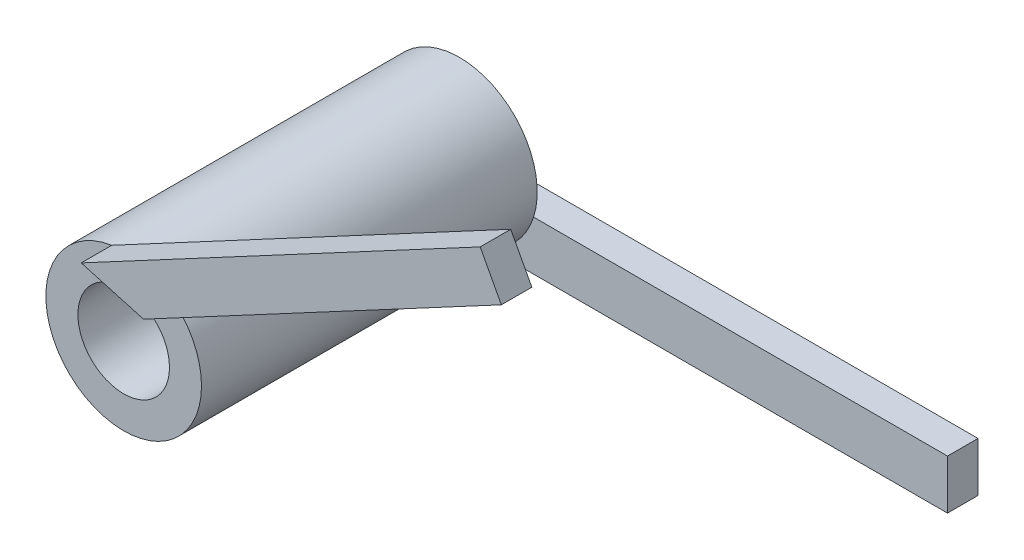
from build123d import *

# Parameters (mm, degrees)
SKETCH1_R      = 2.55
EXTRUDE1_DEPTH = 11
EXTRUDE2_DEPTH = 1
SKETCH3_W      = 15.099881368
SKETCH3_H      = 1.61958708
EXTRUDE3_DEPTH = 1
SKETCH4_R      = 1.5
EXTRUDE4_DEPTH = 13


with BuildPart() as part:
    # Sketch1 → Extrude1 (new body)
    with BuildSketch(Plane.XY):
        Circle(SKETCH1_R)
    extrude(amount=EXTRUDE1_DEPTH)

    # Sketch2 → Extrude2 (add)
    with BuildSketch(Plane.XY.offset(11)):
        Polygon((1.650889975, 1.943466565), (13.374427377, 8.212697839), (12.680705309, 9.509966398), (-0.390866423, 2.519865758), align=None)
    extrude(amount=EXTRUDE2_DEPTH)

    # Sketch3 → Extrude3 (add)
    with BuildSketch(Plane(origin=(0, 0, 0), x_dir=(-1, 0, 0), z_dir=(0, 0, -1))):
        with Locations((-8.442177906, -1.57901636)):
            Rectangle(SKETCH3_W, SKETCH3_H)
    extrude(amount=EXTRUDE3_DEPTH)

    # Sketch4 → Extrude4 (cut, through all)
    with BuildSketch(Plane.XY.offset(11)):
        Circle(SKETCH4_R)
    extrude(amount=-EXTRUDE4_DEPTH, mode=Mode.SUBTRACT)


solid = part.part
